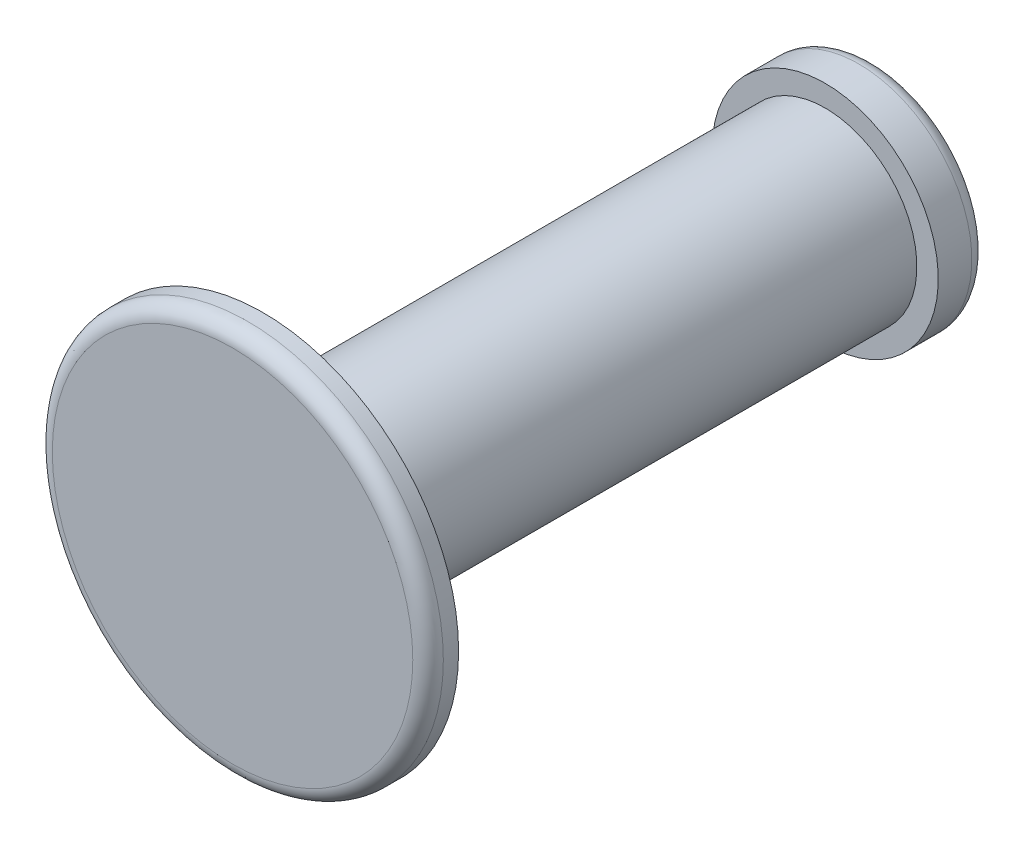
from build123d import *

# Parameters (mm, degrees)
SKETCH1_R      = 0.75
EXTRUDE1_DEPTH = 2.3
SKETCH2_R      = 1.6
EXTRUDE2_DEPTH = 0.25
SKETCH3_R      = 0.925
EXTRUDE3_DEPTH = 0.4
FILLET1_R      = 0.125


with BuildPart() as part:
    # Sketch1 → Extrude1 (new body, symmetric)
    with BuildSketch(Plane.XY):
        Circle(SKETCH1_R)
    extrude(amount=EXTRUDE1_DEPTH, both=True)

    # Sketch2 → Extrude2 (add)
    with BuildSketch(Plane.XY.offset(2.3)):
        Circle(SKETCH2_R)
    extrude(amount=EXTRUDE2_DEPTH)

    # Sketch3 → Extrude3 (add)
    with BuildSketch(Plane(origin=(0, 0, -2.3), x_dir=(-1, 0, 0), z_dir=(0, 0, -1))):
        Circle(SKETCH3_R)
    extrude(amount=EXTRUDE3_DEPTH)

    # Fillet1
    fillet1_edges = [part.edges().sort_by_distance(p)[0] for p in [
        (-1.6, 0, 2.55),
        (0.925, 0, -2.7),
    ]]
    fillet(fillet1_edges, radius=FILLET1_R)


solid = part.part
